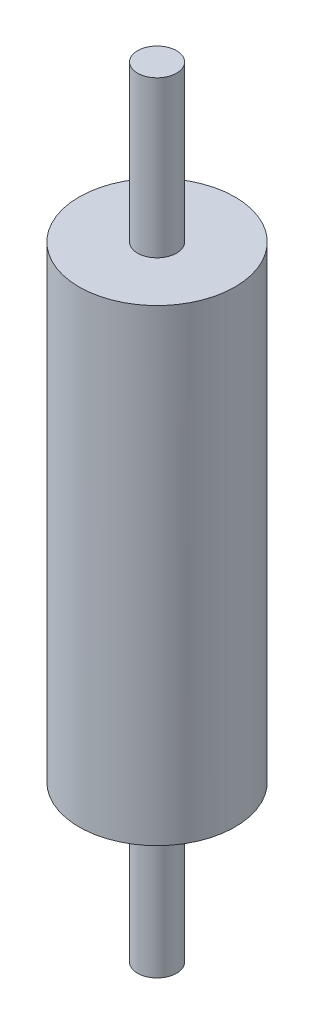
from build123d import *

# Parameters (mm, degrees)
SKETCH1_R           = 10
BOSS_EXTRUDE1_DEPTH = 100
SKETCH2_R           = 10
SKETCH2_R_2         = 2.5
CUT_EXTRUDE2_DEPTH  = 20
SKETCH3_R           = 10
SKETCH3_R_2         = 2.5
CUT_EXTRUDE3_DEPTH  = 20


with BuildPart() as part:
    # Sketch1 → Boss-Extrude1 (new body)
    with BuildSketch(Plane(origin=(0, 0, 0), x_dir=(1, 0, 0), z_dir=(0, 1, 0))):
        Circle(SKETCH1_R)
    extrude(amount=BOSS_EXTRUDE1_DEPTH)

    # Sketch2 → Cut-Extrude2 (cut)
    with BuildSketch(Plane(origin=(0, 100, 0), x_dir=(1, 0, 0), z_dir=(0, 1, 0))):
        Circle(SKETCH2_R)
        Circle(SKETCH2_R_2, mode=Mode.SUBTRACT)
    extrude(amount=-CUT_EXTRUDE2_DEPTH, mode=Mode.SUBTRACT)

    # Sketch3 → Cut-Extrude3 (cut)
    with BuildSketch(Plane.XZ):
        Circle(SKETCH3_R)
        Circle(SKETCH3_R_2, mode=Mode.SUBTRACT)
    extrude(amount=-CUT_EXTRUDE3_DEPTH, mode=Mode.SUBTRACT)


solid = part.part
